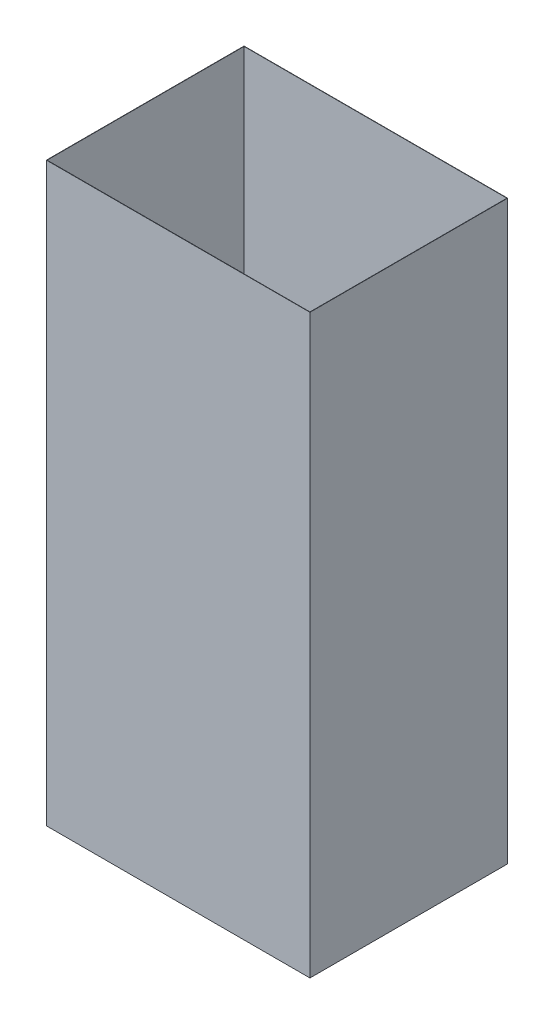
from build123d import *

# Parameters (mm, degrees)
SKETCH1_W           = 406.4
SKETCH1_H           = 304.8
BOSS_EXTRUDE1_DEPTH = 889
SHELL1_T            = -0.508


with BuildPart() as part:
    # Sketch1 → Boss-Extrude1 (new body)
    with BuildSketch(Plane(origin=(0, 0, 0), x_dir=(1, 0, 0), z_dir=(0, 1, 0))):
        Rectangle(SKETCH1_W, SKETCH1_H)
    extrude(amount=BOSS_EXTRUDE1_DEPTH)

    # Shell1
    shell1_openings = [part.faces().sort_by_distance(p)[0] for p in [
        (0, 889, 0),
    ]]
    offset(amount=SHELL1_T, openings=shell1_openings, kind=Kind.INTERSECTION)


solid = part.part
